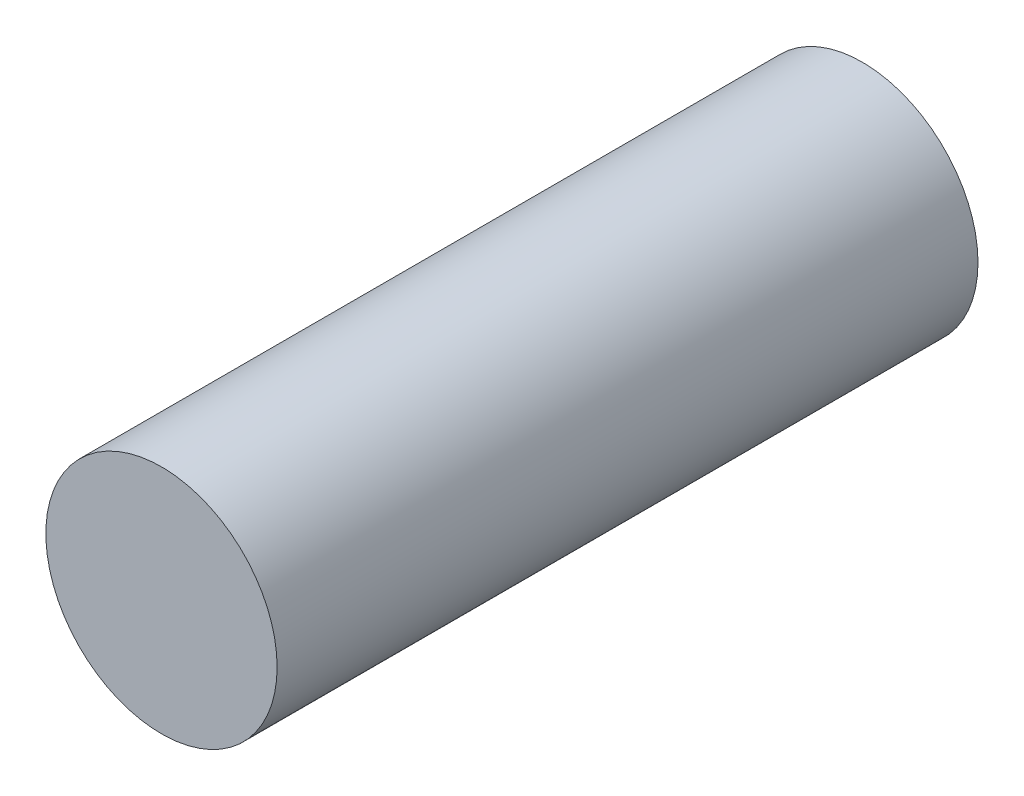
from build123d import *

# Parameters (mm, degrees)
SKICA1_R                = 1.65
P_IDAT_VYSUNUT_M1_DEPTH = 10


with BuildPart() as part:
    # Skica1 → Přidat vysunutím1 (new body)
    with BuildSketch(Plane.XY):
        Circle(SKICA1_R)
    extrude(amount=P_IDAT_VYSUNUT_M1_DEPTH)


solid = part.part
